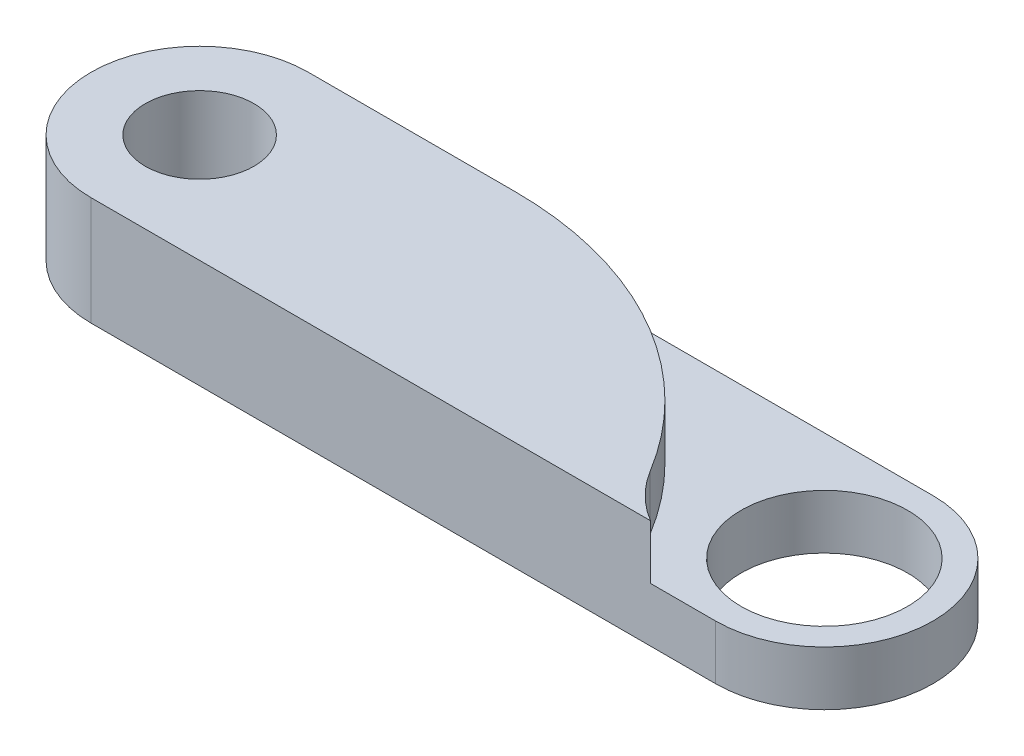
from build123d import *

# Parameters (mm, degrees)
SKETCH_1_R          = 3
SKETCH_1_R_2        = 4.6
EXTRUDE_1_DEPTH     = 6
SKETCH_3_R          = 7
CUT_EXTRUDE_1_DEPTH = 3
FILLET_1_R          = 20


with BuildPart() as part:
    # ｽｹｯﾁ1 → ﾎﾞｽ - 押し出し1 (new body)
    with BuildSketch(Plane(origin=(0, 0, 0), x_dir=(1, 0, 0), z_dir=(0, 1, 0))):
        with BuildLine():
            Line((-17.25, 6), (17.25, 6))
            ThreePointArc((17.25, 6), (23.25, 0), (17.25, -6))
            Line((17.25, -6), (-17.25, -6))
            ThreePointArc((-17.25, -6), (-23.25, 0), (-17.25, 6))
        make_face()
        with Locations((-17.25, 0)):
            Circle(SKETCH_1_R, mode=Mode.SUBTRACT)
        with Locations((17.25, 0)):
            Circle(SKETCH_1_R_2, mode=Mode.SUBTRACT)
    extrude(amount=EXTRUDE_1_DEPTH)

    # ｽｹｯﾁ3 → ｶｯﾄ - 押し出し1 (cut)
    with BuildSketch(Plane(origin=(0, 6, 0), x_dir=(1, 0, 0), z_dir=(0, 1, 0))):
        with Locations((17.25, 0)):
            Circle(SKETCH_3_R)
    extrude(amount=-CUT_EXTRUDE_1_DEPTH, mode=Mode.SUBTRACT)

    # ﾌｨﾚｯﾄ1
    fillet_1_edges = [part.edges().sort_by_distance(p)[0] for p in [
        (13.644448725, 4.5, -6),
    ]]
    fillet(fillet_1_edges, radius=FILLET_1_R)


solid = part.part
